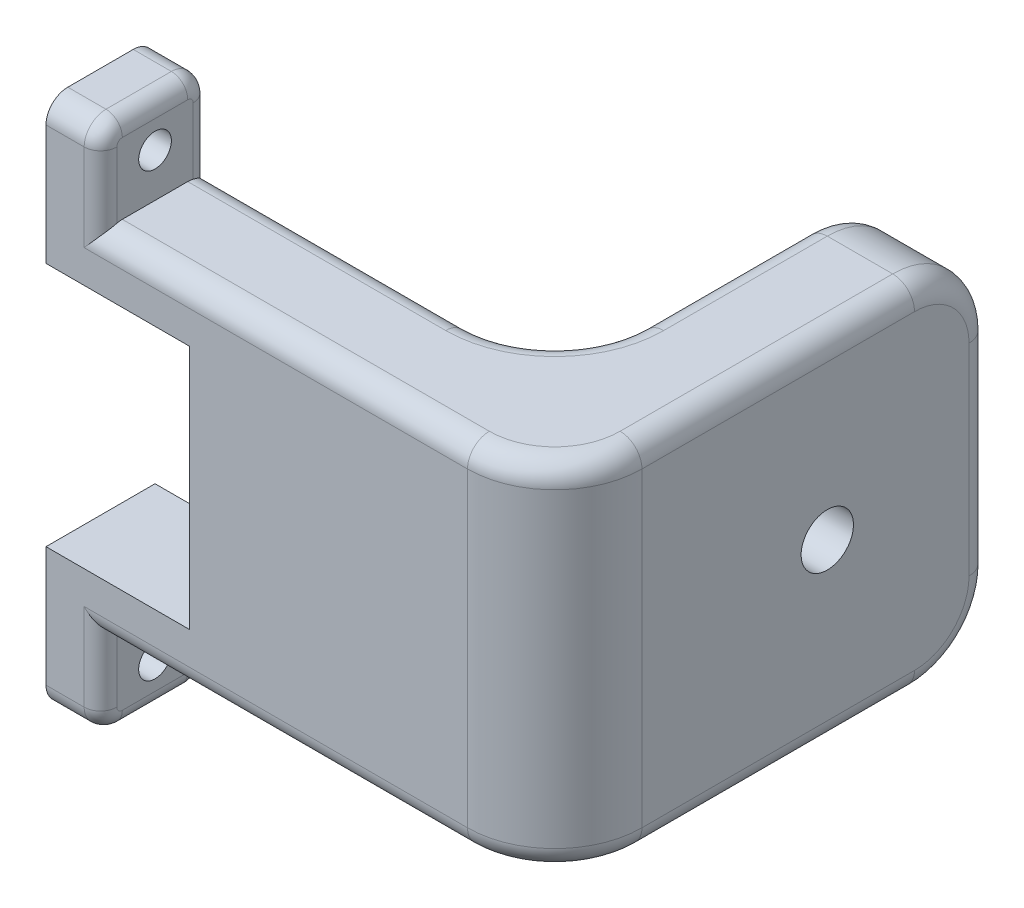
from build123d import *

# Parameters (mm, degrees)
BOSS_EXTRUDE1_DEPTH = 15
SKETCH2_W           = 15
SKETCH2_H           = 32.5
BOSS_EXTRUDE2_DEPTH = 30
SKETCH3_W           = 10
SKETCH3_H           = 32.5
BOSS_EXTRUDE3_DEPTH = 30
SKETCH4_R           = 2.4
CUT_EXTRUDE1_DEPTH  = 5
CUT_EXTRUDE2_DEPTH  = 5
FILLET1_R           = 7
FILLET2_R           = 8
BOSS_EXTRUDE4_DEPTH = 5
SKETCH7_R           = 1.5
CUT_EXTRUDE3_DEPTH  = 6
FILLET3_R           = 2
FILLET4_R           = 1.5


with BuildPart() as part:
    # Sketch1 → Boss-Extrude1 (new body)
    with BuildSketch(Plane.XY):
        Polygon((-7.003618791, -14.915819089), (6.175, -14.915819089), (6.175, 7.584180911), (-7.003618791, 7.584180911), (-7.003618791, 12.584180911), (9.659757463, 12.584180911), (9.659757463, -19.915819089), (-7.003618791, -19.915819089), align=None)
    extrude(amount=BOSS_EXTRUDE1_DEPTH)

    # Sketch2 → Boss-Extrude2 (add)
    with BuildSketch(Plane(origin=(9.659757463, 0, 0), x_dir=(0, 0, -1), z_dir=(1, 0, 0))):
        with Locations((-7.5, -3.665819089)):
            Rectangle(SKETCH2_W, SKETCH2_H)
    extrude(amount=BOSS_EXTRUDE2_DEPTH)

    # Sketch3 → Boss-Extrude3 (add)
    with BuildSketch(Plane(origin=(0, 0, 0), x_dir=(-1, 0, 0), z_dir=(0, 0, -1))):
        with Locations((-34.659757463, -3.665819089)):
            Rectangle(SKETCH3_W, SKETCH3_H)
    extrude(amount=BOSS_EXTRUDE3_DEPTH)

    # Sketch4 → Cut-Extrude1 (cut)
    with BuildSketch(Plane(origin=(39.659757463, 0, 0), x_dir=(0, 0, -1), z_dir=(1, 0, 0))):
        with Locations((15, -3.53982496)):
            Circle(SKETCH4_R)
    extrude(amount=-CUT_EXTRUDE1_DEPTH, mode=Mode.SUBTRACT)

    # Sketch5 → Cut-Extrude2 (cut)
    with BuildSketch(Plane.XY.offset(15)):
        Polygon((39.659757463, 12.584180911), (-7.003618791, 12.584180911), (-7.003618791, 7.584180911), (6.175, 7.584180911), (6.175, -14.915819089), (-7.003618791, -14.915819089), (-7.003618791, -19.915819089), (39.659757463, -19.915819089), align=None)
    extrude(amount=-CUT_EXTRUDE2_DEPTH, mode=Mode.SUBTRACT)

    # Fillet1
    fillet1_edges = [part.edges().sort_by_distance(p)[0] for p in [
        (34.659757463, -19.915819089, -30),
        (34.659757463, 12.584180911, -30),
    ]]
    fillet(fillet1_edges, radius=FILLET1_R)

    # Fillet2
    fillet2_edges = [part.edges().sort_by_distance(p)[0] for p in [
        (29.659757463, -3.665819089, 0),
        (39.659757463, -3.665819089, 10),
    ]]
    fillet(fillet2_edges, radius=FILLET2_R)

    # Sketch6 → Boss-Extrude4 (add)
    with BuildSketch(Plane.ZY.offset(7.003618791)):
        with BuildLine():
            Line((0, 7.584180911), (10, 7.584180911))
            Line((10, 7.584180911), (10, 18.584180911))
            ThreePointArc((10, 18.584180911), (9.414213562, 19.998394474), (8, 20.584180911))
            Line((8, 20.584180911), (2, 20.584180911))
            ThreePointArc((2, 20.584180911), (0.585786438, 19.998394474), (0, 18.584180911))
            Line((0, 18.584180911), (0, 7.584180911))
        make_face()
        with BuildLine():
            Line((10, -14.915819089), (10, -25.915819089))
            ThreePointArc((10, -25.915819089), (9.414213562, -27.330032651), (8, -27.915819089))
            Line((8, -27.915819089), (2, -27.915819089))
            ThreePointArc((2, -27.915819089), (0.585786438, -27.330032651), (0, -25.915819089))
            Line((0, -25.915819089), (0, -14.915819089))
            Line((0, -14.915819089), (10, -14.915819089))
        make_face()
    extrude(amount=-BOSS_EXTRUDE4_DEPTH)

    # Sketch7 → Cut-Extrude3 (cut, through all)
    with BuildSketch(Plane(origin=(-2.003618791, 0, 0), x_dir=(0, 0, -1), z_dir=(1, 0, 0))):
        with Locations((-5, -23.915819089)):
            Circle(SKETCH7_R)
        with Locations((-5, 16.584180911)):
            Circle(SKETCH7_R)
    extrude(amount=-CUT_EXTRUDE3_DEPTH, mode=Mode.SUBTRACT)

    # Fillet3
    fillet3_edges = [part.edges().sort_by_distance(p)[0] for p in [
        (14.828069336, 12.584180911, 10),
        (9.828069336, 12.584180911, 0),
        (37.316611713, 12.584180911, 7.656854249),
        (39.659757463, -19.915819089, -10.5),
        (37.316611713, -19.915819089, 7.656854249),
        (27.316611713, 12.584180911, -2.343145751),
        (27.316611713, -19.915819089, -2.343145751),
        (14.828069336, -19.915819089, 10),
        (9.828069336, -19.915819089, 0),
        (39.659757463, -3.665819089, -30),
        (29.659757463, -3.665819089, -30),
        (39.659757463, 12.584180911, -10.5),
        (39.659757463, -17.865566557, -27.949747468),
        (39.659757463, 10.53392838, -27.949747468),
        (29.659757463, 12.584180911, -15.5),
        (29.659757463, -19.915819089, -15.5),
        (29.659757463, -17.865566557, -27.949747468),
        (29.659757463, 10.53392838, -27.949747468),
    ]]
    fillet(fillet3_edges, radius=FILLET3_R)

    # Fillet4
    fillet4_edges = [part.edges().sort_by_distance(p)[0] for p in [
        (-2.003618791, 15.584180911, 0),
        (-2.003618791, 15.584180911, 10),
        (-2.003618791, 19.998394474, 0.585786438),
        (-2.003618791, 20.584180911, 5),
        (-2.003618791, 19.998394474, 9.414213562),
        (-2.003618791, -22.915819089, 10),
        (-2.003618791, -22.915819089, 0),
        (-2.003618791, -27.330032651, 9.414213562),
        (-2.003618791, -27.915819089, 5),
        (-2.003618791, -27.330032651, 0.585786438),
    ]]
    fillet(fillet4_edges, radius=FILLET4_R)


solid = part.part
